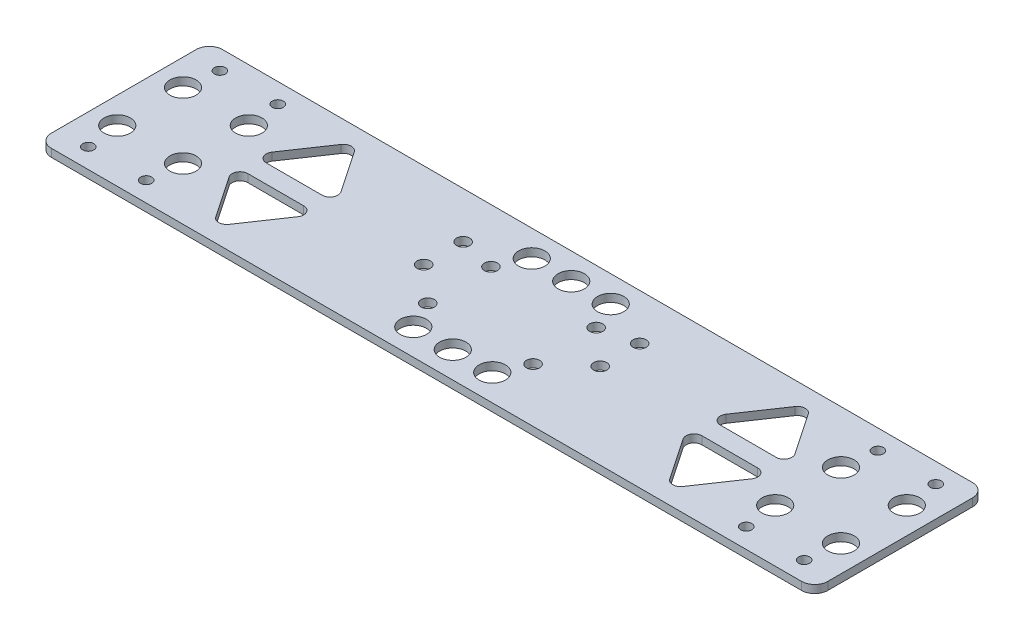
from build123d import *

# Parameters (mm, degrees)
SKETCH_1_W             = 295
SKETCH_1_H             = 65
SKETCH_1_R             = 2.5
EXTRUDE_1_DEPTH        = 3
SKETCH_4_R             = 5
CUT_EXTRUDE_2_DEPTH    = 15
SKETCH_6_R             = 2.1
CUT_EXTRUDE_4_DEPTH    = 10
SKETCH_7_R             = 7.5
SKETCH_7_R_2           = 5
CUT_EXTRUDE_5_DEPTH    = 10
FILLET_1_R             = 3
FILLET_2_R             = 5
EXTRUDE_3_DEPTH        = 3
EXTRUDE_4_DEPTH        = 3
SKETCH_10_R            = 7.5
EXTRUDE_5_DEPTH        = 3
SKETCH_12_R            = 2.498260172
SKETCH_12_R_2          = 2.5
EXTRUDE_6_DEPTH        = 3
SKETCH_14_R            = 7.5
EXTRUDE_7_DEPTH        = 3
SKETCH_16_R            = 2.5
CUT_EXTRUDE_9_DEPTH    = 4
FILLET_1_OF_MIRROR_4_R = 3
SKETCH_17_R            = 7.5
EXTRUDE_9_DEPTH        = 3
SKETCH_18_R            = 5
EXTRUDE_10_DEPTH       = 3
SKETCH_19_R            = 2.499999993
SKETCH_19_R_2          = 2.5
CUT_EXTRUDE_10_DEPTH   = 10


with BuildPart() as part:
    # 草图1 → 凸台-拉伸1 (new body)
    with BuildSketch(Plane(origin=(0, 0, 0), x_dir=(1, 0, 0), z_dir=(0, 1, 0))):
        Rectangle(SKETCH_1_W, SKETCH_1_H)
        with Locations((-137.5, 12.5)):
            Circle(SKETCH_1_R, mode=Mode.SUBTRACT)
        with Locations((-112.5, 12.5)):
            Circle(SKETCH_1_R, mode=Mode.SUBTRACT)
        with Locations((-137.5, -12.5)):
            Circle(SKETCH_1_R, mode=Mode.SUBTRACT)
        with Locations((-112.5, -12.5)):
            Circle(SKETCH_1_R, mode=Mode.SUBTRACT)
        with Locations((-20, 12)):
            Circle(SKETCH_1_R, mode=Mode.SUBTRACT)
        with Locations((-20, -12)):
            Circle(SKETCH_1_R, mode=Mode.SUBTRACT)
        with Locations((20, -12)):
            Circle(SKETCH_1_R, mode=Mode.SUBTRACT)
        with Locations((20, 12)):
            Circle(SKETCH_1_R, mode=Mode.SUBTRACT)
        with Locations((112.5, -12.5)):
            Circle(SKETCH_1_R, mode=Mode.SUBTRACT)
        with Locations((137.5, -12.5)):
            Circle(SKETCH_1_R, mode=Mode.SUBTRACT)
        with Locations((112.5, 12.5)):
            Circle(SKETCH_1_R, mode=Mode.SUBTRACT)
        with Locations((137.5, 12.5)):
            Circle(SKETCH_1_R, mode=Mode.SUBTRACT)
    extrude(amount=EXTRUDE_1_DEPTH)

    # 草图4 → 切除-拉伸2 (cut)
    with BuildSketch(Plane(origin=(0, 3, 0), x_dir=(1, 0, 0), z_dir=(0, 1, 0))):
        with Locations((112.5, -12.5)):
            Circle(SKETCH_4_R)
        with Locations((112.5, 12.5)):
            Circle(SKETCH_4_R)
        with Locations((137.5, -12.5)):
            Circle(SKETCH_4_R)
        with Locations((137.5, 12.5)):
            Circle(SKETCH_4_R)
        with Locations((-137.5, 12.5)):
            Circle(SKETCH_4_R)
        with Locations((-137.5, -12.5)):
            Circle(SKETCH_4_R)
        with Locations((-112.5, 12.5)):
            Circle(SKETCH_4_R)
        with Locations((-112.5, -12.5)):
            Circle(SKETCH_4_R)
    extrude(amount=-CUT_EXTRUDE_2_DEPTH, mode=Mode.SUBTRACT)

    # 草图6 → 切除-拉伸4 (cut)
    with BuildSketch(Plane(origin=(0, 3, 0), x_dir=(1, 0, 0), z_dir=(0, 1, 0))):
        with Locations((136, -25)):
            Circle(SKETCH_6_R)
        with Locations((-136, -25)):
            Circle(SKETCH_6_R)
        with Locations((-136, 25)):
            Circle(SKETCH_6_R)
        with Locations((136, 25)):
            Circle(SKETCH_6_R)
        with Locations((114, -25)):
            Circle(SKETCH_6_R)
        with Locations((-114, -25)):
            Circle(SKETCH_6_R)
        with Locations((114, 25)):
            Circle(SKETCH_6_R)
        with Locations((-114, 25)):
            Circle(SKETCH_6_R)
    extrude(amount=-CUT_EXTRUDE_4_DEPTH, mode=Mode.SUBTRACT)

    # 草图7 → 切除-拉伸5 (cut)
    with BuildSketch(Plane(origin=(0, 3, 0), x_dir=(1, 0, 0), z_dir=(0, 1, 0))):
        with Locations((-66.25, 19.5)):
            Circle(SKETCH_7_R)
        with Locations((-66.25, -19.5)):
            Circle(SKETCH_7_R)
        with Locations((66.25, 19.5)):
            Circle(SKETCH_7_R)
        with Locations((66.25, -19.5)):
            Circle(SKETCH_7_R)
        with Locations((-30, 22.5)):
            Circle(SKETCH_7_R_2)
        with Locations((-15, 22.5)):
            Circle(SKETCH_7_R_2)
        with Locations((15, 22.5)):
            Circle(SKETCH_7_R_2)
        with Locations((30, 22.5)):
            Circle(SKETCH_7_R_2)
        with Locations((-30, -22.5)):
            Circle(SKETCH_7_R_2)
        with Locations((-15, -22.5)):
            Circle(SKETCH_7_R_2)
        with Locations((15, -22.5)):
            Circle(SKETCH_7_R_2)
        with Locations((30, -22.5)):
            Circle(SKETCH_7_R_2)
        with Locations((0, 22.5)):
            Circle(SKETCH_7_R_2)
        with Locations((0, -22.5)):
            Circle(SKETCH_7_R_2)
        Polygon((-86.25, 27.5), (-102.5, 3.5), (-70, 3.5), align=None)
        Polygon((-30, 3.5), (-62.5, 3.5), (-46.25, 27.5), align=None)
        Polygon((-102.5, -3.5), (-70, -3.5), (-86.25, -27.5), align=None)
        Polygon((-46.25, -27.5), (-30, -3.5), (-62.5, -3.5), align=None)
        Polygon((46.25, 27.5), (30, 3.5), (62.5, 3.5), align=None)
        Polygon((102.5, 3.5), (70, 3.5), (86.25, 27.5), align=None)
        Polygon((86.25, -27.5), (102.5, -3.5), (70, -3.5), align=None)
        Polygon((62.5, -3.5), (46.25, -27.5), (30, -3.5), align=None)
    cut_extrude_5 = extrude(amount=-CUT_EXTRUDE_5_DEPTH, mode=Mode.SUBTRACT)

    # 圆角1
    fillet_1_edges = [part.edges().sort_by_distance(p)[0] for p in [
        (86.25, 1.5, -27.5),
        (102.5, 1.5, -3.5),
        (70, 1.5, -3.5),
        (86.25, 1.5, 27.5),
        (70, 1.5, 3.5),
        (102.5, 1.5, 3.5),
        (30, 1.5, 3.5),
        (62.5, 1.5, 3.5),
        (46.25, 1.5, 27.5),
        (-46.25, 1.5, -27.5),
        (-30, 1.5, -3.5),
        (-62.5, 1.5, -3.5),
        (-86.25, 1.5, 27.5),
        (-102.5, 1.5, 3.5),
        (-70, 1.5, 3.5),
        (46.25, 1.5, -27.5),
        (62.5, 1.5, -3.5),
        (30, 1.5, -3.5),
        (-46.25, 1.5, 27.5),
        (-62.5, 1.5, 3.5),
        (-30, 1.5, 3.5),
        (-86.25, 1.5, -27.5),
        (-70, 1.5, -3.5),
        (-102.5, 1.5, -3.5),
    ]]
    fillet(fillet_1_edges, radius=FILLET_1_R)

    # 圆角2
    fillet_2_edges = [part.edges().sort_by_distance(p)[0] for p in [
        (147.5, 1.5, 32.5),
        (-147.5, 1.5, 32.5),
        (-147.5, 1.5, -32.5),
        (147.5, 1.5, -32.5),
    ]]
    fillet(fillet_2_edges, radius=FILLET_2_R)

    # 草图8 → 凸台-拉伸3 (add)
    with BuildSketch(Plane.XZ):
        with BuildLine():
            Line((-88.734143599, 23.831110992), (-99.329914637, 8.181972229))
            ThreePointArc((-99.329914637, 8.181972229), (-99.495857516, 5.093926866), (-96.845771038, 3.5))
            Line((-96.845771038, 3.5), (-75.654228962, 3.5))
            ThreePointArc((-75.654228962, 3.5), (-73.004142484, 5.093926866), (-73.170085363, 8.181972229))
            Line((-73.170085363, 8.181972229), (-83.765856401, 23.831110992))
            ThreePointArc((-83.765856401, 23.831110992), (-86.25, 25.149138763), (-88.734143599, 23.831110992))
        make_face()
    extrude(amount=-EXTRUDE_3_DEPTH)

    # 草图9 → 凸台-拉伸4 (add)
    with BuildSketch(Plane.XZ):
        with BuildLine():
            Line((-88.734143599, -23.831110992), (-99.329914637, -8.181972229))
            ThreePointArc((-99.329914637, -8.181972229), (-99.495857516, -5.093926866), (-96.845771038, -3.5))
            Line((-96.845771038, -3.5), (-75.654228962, -3.5))
            ThreePointArc((-75.654228962, -3.5), (-73.004142484, -5.093926866), (-73.170085363, -8.181972229))
            Line((-73.170085363, -8.181972229), (-83.765856401, -23.831110992))
            ThreePointArc((-83.765856401, -23.831110992), (-86.25, -25.149138763), (-88.734143599, -23.831110992))
        make_face()
    extrude(amount=-EXTRUDE_4_DEPTH)

    # 草图10 → 凸台-拉伸5 (add)
    with BuildSketch(Plane.XZ):
        with Locations((-66.25, -19.5)):
            Circle(SKETCH_10_R)
        with Locations((-66.25, 19.5)):
            Circle(SKETCH_10_R)
    extrude(amount=-EXTRUDE_5_DEPTH)

    # 草图12 → 凸台-拉伸6 (add)
    with BuildSketch(Plane.XZ):
        with Locations((-20, -12)):
            Circle(SKETCH_12_R)
        with Locations((-20, 12)):
            Circle(SKETCH_12_R_2)
        with Locations((20, -12)):
            Circle(SKETCH_12_R_2)
        with Locations((20, 12)):
            Circle(SKETCH_12_R_2)
    extrude(amount=-EXTRUDE_6_DEPTH)

    # 草图14 → 凸台-拉伸7 (add)
    with BuildSketch(Plane.XZ):
        with Locations((66.25, -19.5)):
            Circle(SKETCH_14_R)
        with Locations((66.25, 19.5)):
            Circle(SKETCH_14_R)
    extrude(amount=-EXTRUDE_7_DEPTH)

    # 草图16 → 切除-拉伸9 (cut, through all)
    with BuildSketch(Plane(origin=(0, 3, 0), x_dir=(1, 0, 0), z_dir=(0, 1, 0))):
        with Locations((-20, -12)):
            Circle(SKETCH_16_R)
        with Locations((-20, 12)):
            Circle(SKETCH_16_R)
        with Locations((20, -12)):
            Circle(SKETCH_16_R)
        with Locations((20, 12)):
            Circle(SKETCH_16_R)
    extrude(amount=-CUT_EXTRUDE_9_DEPTH, mode=Mode.SUBTRACT)

    # 镜向4: 切除-拉伸5 across plane
    add(cut_extrude_5.mirror(Plane(origin=(0, 0, 0), x_dir=(0, 0, 1), z_dir=(1, 0, 0))), mode=Mode.SUBTRACT)

    # 圆角1 of 镜向4
    fillet_1_of_mirror_4_edges = [part.edges().sort_by_distance(p)[0] for p in [
        (-86.25, 1.5, -27.5),
        (-102.5, 1.5, -3.5),
        (-70, 1.5, -3.5),
        (-86.25, 1.5, 27.5),
        (-70, 1.5, 3.5),
        (-102.5, 1.5, 3.5),
        (-30, 1.5, 3.5),
        (-62.5, 1.5, 3.5),
        (-46.25, 1.5, 27.5),
        (46.25, 1.5, -27.5),
        (30, 1.5, -3.5),
        (62.5, 1.5, -3.5),
        (86.25, 1.5, 27.5),
        (102.5, 1.5, 3.5),
        (70, 1.5, 3.5),
        (-46.25, 1.5, -27.5),
        (-62.5, 1.5, -3.5),
        (-30, 1.5, -3.5),
        (46.25, 1.5, 27.5),
        (62.5, 1.5, 3.5),
        (30, 1.5, 3.5),
        (86.25, 1.5, -27.5),
        (70, 1.5, -3.5),
        (102.5, 1.5, -3.5),
    ]]
    fillet(fillet_1_of_mirror_4_edges, radius=FILLET_1_OF_MIRROR_4_R)

    # 草图17 → 凸台-拉伸9 (add)
    with BuildSketch(Plane(origin=(0, 3, 0), x_dir=(1, 0, 0), z_dir=(0, 1, 0))):
        with Locations((-66.25, 19.5)):
            Circle(SKETCH_17_R)
        with Locations((-66.25, -19.5)):
            Circle(SKETCH_17_R)
        with Locations((66.25, 19.5)):
            Circle(SKETCH_17_R)
        with Locations((66.25, -19.5)):
            Circle(SKETCH_17_R)
        with BuildLine():
            Line((-48.734143599, 23.831110992), (-59.329914637, 8.181972229))
            ThreePointArc((-59.329914637, 8.181972229), (-59.495857516, 5.093926866), (-56.845771038, 3.5))
            Line((-56.845771038, 3.5), (-35.654228962, 3.5))
            ThreePointArc((-35.654228962, 3.5), (-33.004142484, 5.093926866), (-33.170085363, 8.181972229))
            Line((-33.170085363, 8.181972229), (-43.765856401, 23.831110992))
            ThreePointArc((-43.765856401, 23.831110992), (-46.25, 25.149138763), (-48.734143599, 23.831110992))
        make_face()
        with BuildLine():
            Line((-56.845771038, -3.5), (-35.654228962, -3.5))
            ThreePointArc((-35.654228962, -3.5), (-33.004142484, -5.093926866), (-33.170085363, -8.181972229))
            Line((-33.170085363, -8.181972229), (-43.765856401, -23.831110992))
            ThreePointArc((-43.765856401, -23.831110992), (-46.25, -25.149138763), (-48.734143599, -23.831110992))
            Line((-48.734143599, -23.831110992), (-59.329914637, -8.181972229))
            ThreePointArc((-59.329914637, -8.181972229), (-59.495857516, -5.093926866), (-56.845771038, -3.5))
        make_face()
        with BuildLine():
            Line((43.765856401, 23.831110992), (33.170085363, 8.181972229))
            ThreePointArc((33.170085363, 8.181972229), (33.004142484, 5.093926866), (35.654228962, 3.5))
            Line((35.654228962, 3.5), (56.845771038, 3.5))
            ThreePointArc((56.845771038, 3.5), (59.495857516, 5.093926866), (59.329914637, 8.181972229))
            Line((59.329914637, 8.181972229), (48.734143599, 23.831110992))
            ThreePointArc((48.734143599, 23.831110992), (46.25, 25.149138763), (43.765856401, 23.831110992))
        make_face()
        with BuildLine():
            Line((35.654228962, -3.5), (56.845771038, -3.5))
            ThreePointArc((56.845771038, -3.5), (59.495857516, -5.093926866), (59.329914637, -8.181972229))
            Line((59.329914637, -8.181972229), (48.734143599, -23.831110992))
            ThreePointArc((48.734143599, -23.831110992), (46.25, -25.149138763), (43.765856401, -23.831110992))
            Line((43.765856401, -23.831110992), (33.170085363, -8.181972229))
            ThreePointArc((33.170085363, -8.181972229), (33.004142484, -5.093926866), (35.654228962, -3.5))
        make_face()
    extrude(amount=-EXTRUDE_9_DEPTH)

    # 草图18 → 凸台-拉伸10 (add)
    with BuildSketch(Plane.XZ):
        with Locations((-30, -22.5)):
            Circle(SKETCH_18_R)
        with Locations((30, -22.5)):
            Circle(SKETCH_18_R)
        with Locations((30, 22.5)):
            Circle(SKETCH_18_R)
        with Locations((-30, 22.5)):
            Circle(SKETCH_18_R)
    extrude(amount=-EXTRUDE_10_DEPTH)

    # 草图19 → 切除-拉伸10 (cut)
    with BuildSketch(Plane(origin=(0, 0, 0), x_dir=(-1, 0, 0), z_dir=(0, -1, 0))):
        with Locations((-33.500000037, 14.99999998)):
            Circle(SKETCH_19_R)
        with Locations((-33.500000051, 0)):
            Circle(SKETCH_19_R_2)
        with Locations((33.499999962, 14.937012041)):
            Circle(SKETCH_19_R_2)
        with Locations((33.499999962, -0.062987959)):
            Circle(SKETCH_19_R_2)
    extrude(amount=-CUT_EXTRUDE_10_DEPTH, mode=Mode.SUBTRACT)


solid = part.part
